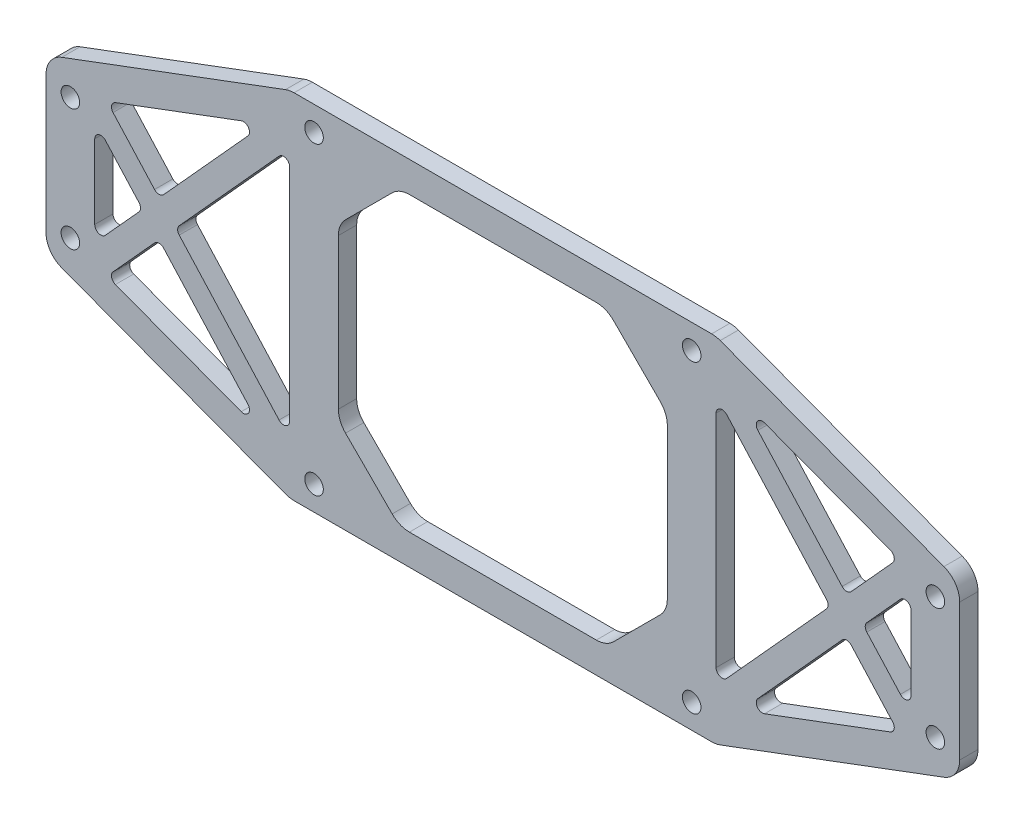
from build123d import *

# Parameters (mm, degrees)
SKETCH_1_W          = 40
SKETCH_1_H          = 28
SKETCH_1_R          = 1.525
SKETCH_1_W_2        = 70
SKETCH_1_H_2        = 15
EXTRUDE_1_DEPTH     = 3
FILLET_1_R          = 4
SKETCH_2_W          = 54
SKETCH_2_H          = 48
CUT_EXTRUDE_1_DEPTH = 3
CHAMFER_1_SIZE      = 10
FILLET_2_R          = 4
FILLET_3_R          = 1


with BuildPart() as part:
    # 草图1 → 凸台-拉伸1 (new body)
    with BuildSketch(Plane.XY):
        Polygon((-35, 29), (-75, 14), (-35, 14), align=None)
        with Locations((-55, 0)):
            Rectangle(SKETCH_1_W, SKETCH_1_H)
        with Locations((-71, -10)):
            Circle(SKETCH_1_R, mode=Mode.SUBTRACT)
        with Locations((-71, 10)):
            Circle(SKETCH_1_R, mode=Mode.SUBTRACT)
        Polygon((-35, -14), (-75, -14), (-35, -29), align=None)
        with Locations((0, -21.5)):
            Rectangle(SKETCH_1_W_2, SKETCH_1_H_2)
        with Locations((-31, -25)):
            Circle(SKETCH_1_R, mode=Mode.SUBTRACT)
        with Locations((31, -25)):
            Circle(SKETCH_1_R, mode=Mode.SUBTRACT)
        Rectangle(SKETCH_1_W_2, SKETCH_1_H)
        with Locations((0, 21.5)):
            Rectangle(SKETCH_1_W_2, SKETCH_1_H_2)
        with Locations((-31, 25)):
            Circle(SKETCH_1_R, mode=Mode.SUBTRACT)
        with Locations((31, 25)):
            Circle(SKETCH_1_R, mode=Mode.SUBTRACT)
        Polygon((75, 14), (35, 29), (35, 14), align=None)
        with Locations((55, 0)):
            Rectangle(SKETCH_1_W, SKETCH_1_H)
        with Locations((71, -10)):
            Circle(SKETCH_1_R, mode=Mode.SUBTRACT)
        with Locations((71, 10)):
            Circle(SKETCH_1_R, mode=Mode.SUBTRACT)
        Polygon((75, -14), (35, -14), (35, -29), align=None)
    extrude(amount=EXTRUDE_1_DEPTH)

    # 圆角1
    fillet_1_edges = [part.edges().sort_by_distance(p)[0] for p in [
        (-35, 29, 1.5),
        (35, 29, 1.5),
        (75, 14, 1.5),
        (75, -14, 1.5),
        (35, -29, 1.5),
        (-35, -29, 1.5),
        (-75, -14, 1.5),
        (-75, 14, 1.5),
    ]]
    fillet(fillet_1_edges, radius=FILLET_1_R)

    # 草图2 → 切除-拉伸1 (cut)
    with BuildSketch(Plane.XY.offset(3)):
        Polygon((-56.436014311, 2.978767355), (-39.087503195, 22.127183961), (-64.985617819, 12.415390977), align=None)
        Polygon((-35, -20.681230304), (-35, 20.681230304), (-53.737243982, 0), align=None)
        Polygon((-39.087503195, -22.127183961), (-56.436014311, -2.978767355), (-64.985617819, -12.415390977), align=None)
        Polygon((-67, -8.681230304), (-59.134784639, 0), (-67, 8.681230304), align=None)
        Rectangle(SKETCH_2_W, SKETCH_2_H)
        Polygon((35, -20.681230304), (53.737243982, 0), (35, 20.681230304), align=None)
        Polygon((39.087503195, 22.127183961), (56.436014311, 2.978767355), (64.985617819, 12.415390977), align=None)
        Polygon((67, -8.681230304), (67, 8.681230304), (59.134784639, 0), align=None)
        Polygon((64.985617819, -12.415390977), (56.436014311, -2.978767355), (39.087503195, -22.127183961), align=None)
    extrude(amount=-CUT_EXTRUDE_1_DEPTH, mode=Mode.SUBTRACT)

    # 倒角1
    chamfer_1_edges = [part.edges().sort_by_distance(p)[0] for p in [
        (-27, -24, 1.5),
        (-27, 24, 1.5),
        (27, 24, 1.5),
        (27, -24, 1.5),
    ]]
    chamfer(chamfer_1_edges, length=CHAMFER_1_SIZE)

    # 圆角2
    fillet_2_edges = [part.edges().sort_by_distance(p)[0] for p in [
        (17, -24, 1.5),
        (-17, -24, 1.5),
        (-27, 14, 1.5),
        (-27, -14, 1.5),
        (27, 14, 1.5),
        (27, -14, 1.5),
        (-17, 24, 1.5),
        (17, 24, 1.5),
    ]]
    fillet(fillet_2_edges, radius=FILLET_2_R)

    # 圆角3
    fillet_3_edges = [part.edges().sort_by_distance(p)[0] for p in [
        (39.087503195, 22.127183961, 1.5),
        (64.985617819, 12.415390977, 1.5),
        (56.436014311, 2.978767355, 1.5),
        (35, -20.681230304, 1.5),
        (35, 20.681230304, 1.5),
        (53.737243982, 0, 1.5),
        (64.985617819, -12.415390977, 1.5),
        (39.087503195, -22.127183961, 1.5),
        (56.436014311, -2.978767355, 1.5),
        (67, 8.681230304, 1.5),
        (67, -8.681230304, 1.5),
        (59.134784639, 0, 1.5),
        (-56.436014311, -2.978767355, 1.5),
        (-39.087503195, -22.127183961, 1.5),
        (-64.985617819, -12.415390977, 1.5),
        (-53.737243982, 0, 1.5),
        (-35, 20.681230304, 1.5),
        (-35, -20.681230304, 1.5),
        (-67, 8.681230304, 1.5),
        (-59.134784639, 0, 1.5),
        (-67, -8.681230304, 1.5),
        (-64.985617819, 12.415390977, 1.5),
        (-39.087503195, 22.127183961, 1.5),
        (-56.436014311, 2.978767355, 1.5),
    ]]
    fillet(fillet_3_edges, radius=FILLET_3_R)


solid = part.part
